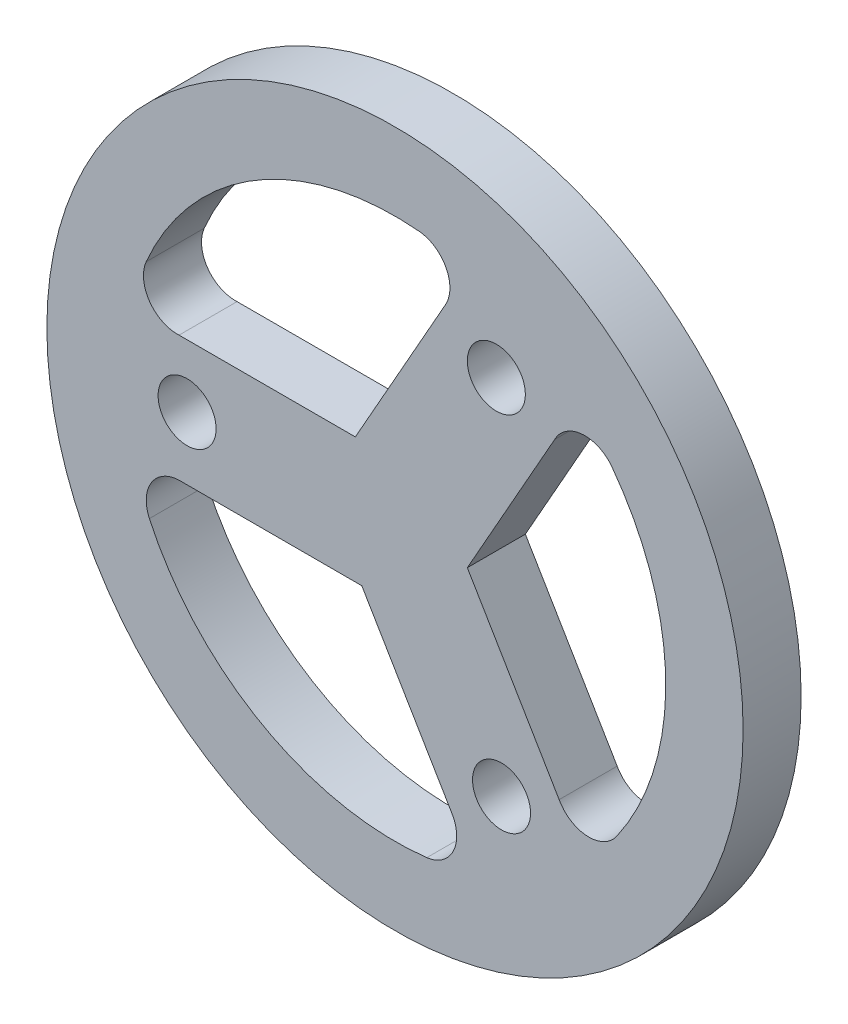
from build123d import *

# Parameters (mm, degrees)
ESQUISSE1_R        = 18
ESQUISSE1_R_2      = 1.5
BOSS_EXTRU_1_DEPTH = 3


with BuildPart() as part:
    # Esquisse1 → Boss.-Extru.1 (new body)
    with BuildSketch(Plane.XY):
        Circle(ESQUISSE1_R)
        with Locations((5.240453276, 9.386167986)):
            Circle(ESQUISSE1_R_2, mode=Mode.SUBTRACT)
        with Locations((5.508433282, -9.231449657)):
            Circle(ESQUISSE1_R_2, mode=Mode.SUBTRACT)
        with Locations((-10.748886558, -0.154718329)):
            Circle(ESQUISSE1_R_2, mode=Mode.SUBTRACT)
        with BuildLine():
            Line((-11.072133243, -3.407490345), (-1.716682497, -3.409655851))
            Line((-1.716682497, -3.409655851), (2.776978064, -10.990617044))
            ThreePointArc((2.776978064, -10.990617044), (2.840789334, -11.103330491), (2.909041031, -11.213411848))
            ThreePointArc((2.909041031, -11.213411848), (3.02444637, -12.90884018), (1.646159643, -13.902883098))
            ThreePointArc((1.646159643, -13.902883098), (-6.824776359, -12.22384668), (-12.698957381, -5.893766319))
            ThreePointArc((-12.698957381, -5.893766319), (-12.575965538, -4.198871447), (-11.072133243, -3.407490345))
        make_face(mode=Mode.SUBTRACT)
        with BuildLine():
            Line((-11.165620039, 3.087402491), (-2.050122008, 3.087402491))
            Line((-2.050122008, 3.087402491), (2.58509342, 11.292493835))
            ThreePointArc((2.58509342, 11.292493835), (2.651653429, 12.990541357), (1.245327334, 13.944502853))
            ThreePointArc((1.245327334, 13.944502853), (-7.173773577, 12.022353042), (-12.86332977, 5.525825479))
            ThreePointArc((-12.86332977, 5.525825479), (-12.691606715, 3.835172702), (-11.165620039, 3.087402491))
        make_face(mode=Mode.SUBTRACT)
        with BuildLine():
            Line((8.487039823, -7.88500349), (3.740322398, 0.12713591))
            Line((3.740322398, 0.12713591), (8.256579008, 8.126009358))
            ThreePointArc((8.256579008, 8.126009358), (9.667160345, 9.073667479), (11.217170127, 8.377057619))
            ThreePointArc((11.217170127, 8.377057619), (13.998549936, 0.201493638), (11.453630047, -8.050736534))
            ThreePointArc((11.453630047, -8.050736534), (9.92431211, -8.79166991), (8.487039823, -7.88500349))
        make_face(mode=Mode.SUBTRACT)
    extrude(amount=BOSS_EXTRU_1_DEPTH)


solid = part.part
